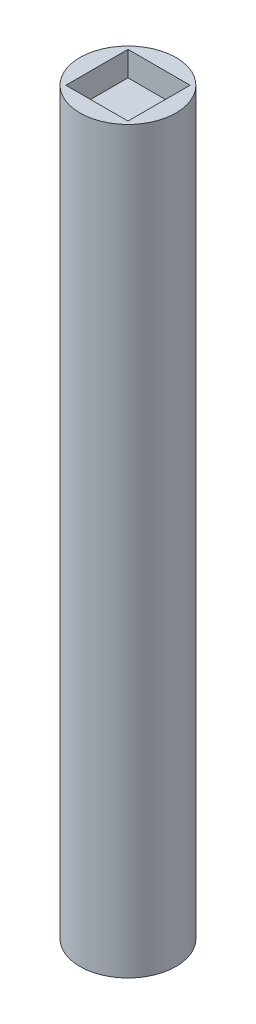
from build123d import *

# Parameters (mm, degrees)
SKETCH1_R           = 4.875
BOSS_EXTRUDE1_DEPTH = 37.5
SKETCH2_W           = 6.3
SKETCH2_H           = 6.3
BOSS_EXTRUDE2_DEPTH = 2.5
SKETCH3_W           = 6.3
SKETCH3_H           = 6.3
CUT_EXTRUDE1_DEPTH  = 5


with BuildPart() as part:
    # Sketch1 → Boss-Extrude1 (new body, symmetric)
    with BuildSketch(Plane(origin=(0, 0, 0), x_dir=(1, 0, 0), z_dir=(0, 1, 0))):
        Circle(SKETCH1_R)
    extrude(amount=BOSS_EXTRUDE1_DEPTH, both=True)

    # Sketch2 → Boss-Extrude2 (add)
    with BuildSketch(Plane(origin=(0, 37.5, 0), x_dir=(1, 0, 0), z_dir=(0, 1, 0))):
        Rectangle(SKETCH2_W, SKETCH2_H)
    extrude(amount=BOSS_EXTRUDE2_DEPTH)

    # Sketch3 → Cut-Extrude1 (cut)
    with BuildSketch(Plane(origin=(0, 40, 0), x_dir=(1, 0, 0), z_dir=(0, 1, 0))):
        Rectangle(SKETCH3_W, SKETCH3_H)
    extrude(amount=-CUT_EXTRUDE1_DEPTH, mode=Mode.SUBTRACT)


solid = part.part
